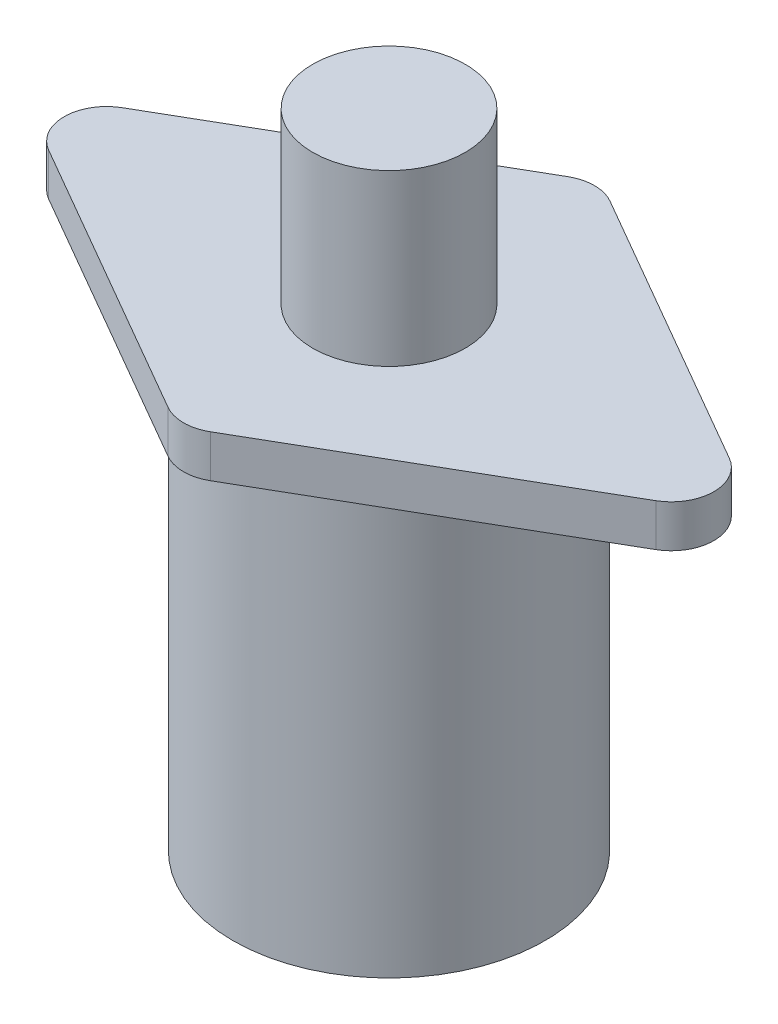
from build123d import *

# Parameters (mm, degrees)
SKETCH1_R           = 18.4
BOSS_EXTRUDE1_DEPTH = 50.8
BOSS_EXTRUDE2_DEPTH = 5
FILLET1_R           = 5
SKETCH3_R           = 9
BOSS_EXTRUDE3_DEPTH = 20


with BuildPart() as part:
    # Sketch1 → Boss-Extrude1 (new body)
    with BuildSketch(Plane(origin=(0, 0, 0), x_dir=(1, 0, 0), z_dir=(0, 1, 0))):
        Circle(SKETCH1_R)
    extrude(amount=BOSS_EXTRUDE1_DEPTH)

    # Sketch2 → Boss-Extrude2 (add)
    with BuildSketch(Plane(origin=(0, 50.8, 0), x_dir=(1, 0, 0), z_dir=(0, 1, 0))):
        Polygon((0, 25), (-43.301270189, 0), (0, -25), (43.301270189, 0), align=None)
    extrude(amount=BOSS_EXTRUDE2_DEPTH)

    # Fillet1
    fillet1_edges = [part.edges().sort_by_distance(p)[0] for p in [
        (43.301270189, 53.3, 0),
        (0, 53.3, -25),
        (-43.301270189, 53.3, 0),
        (0, 53.3, 25),
    ]]
    fillet(fillet1_edges, radius=FILLET1_R)

    # Sketch3 → Boss-Extrude3 (add)
    with BuildSketch(Plane(origin=(0, 55.8, 0), x_dir=(1, 0, 0), z_dir=(0, 1, 0))):
        Circle(SKETCH3_R)
    extrude(amount=BOSS_EXTRUDE3_DEPTH)


solid = part.part
